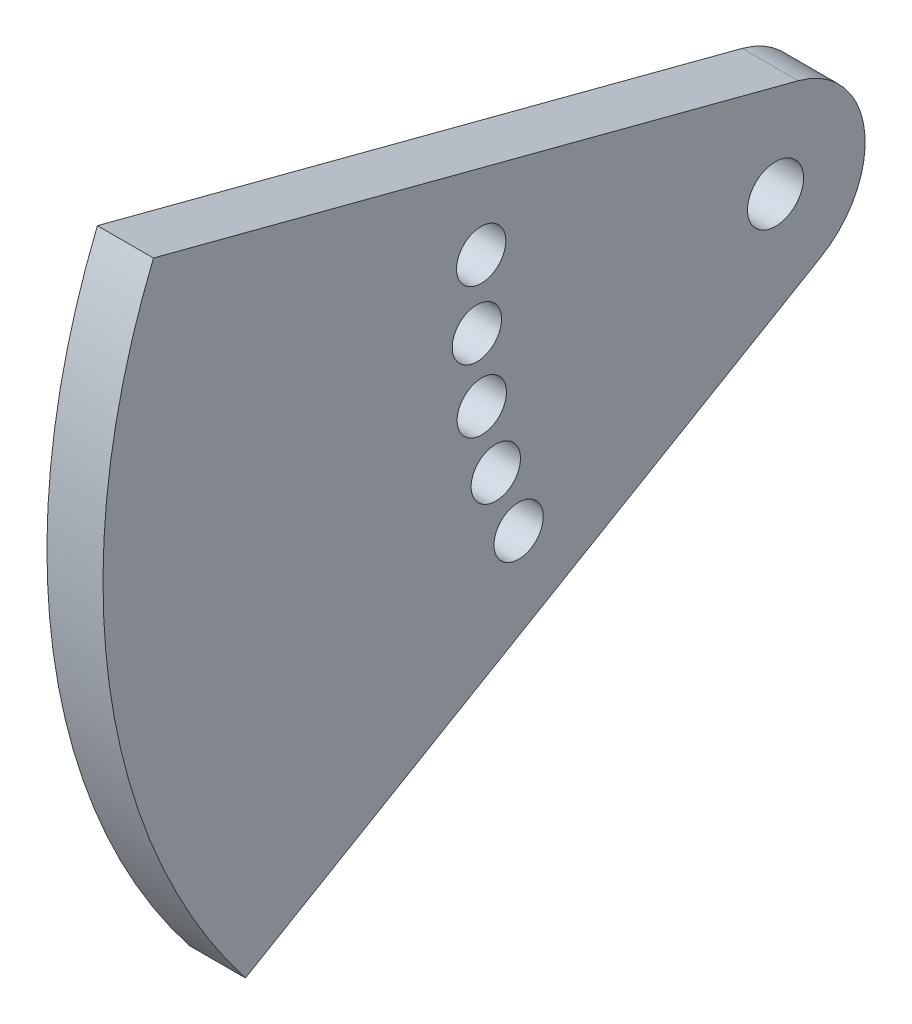
from build123d import *

# Parameters (mm, degrees)
SKETCH1_R           = 2.794
SKETCH1_R_2         = 3.175
BOSS_EXTRUDE1_DEPTH = 6.35


with BuildPart() as part:
    # Sketch1 → Boss-Extrude1 (new body)
    with BuildSketch(Plane(origin=(0, 0, 0), x_dir=(0, 0, -1), z_dir=(1, 0, 0))):
        with BuildLine():
            Line((2.573887506, 9.828565669), (-70.482178955, 28.960359974))
            ThreePointArc((-70.482178955, 28.960359974), (-75.490460705, -10.374504448), (-60.056829366, -46.900077255))
            Line((-60.056829366, -46.900077255), (5.129832124, -8.769858743))
            ThreePointArc((5.129832124, -8.769858743), (10.065394761, 1.38326726), (2.573887506, 9.828565669))
        make_face()
        with Locations((-33.347167041, 10.699986838)):
            Circle(SKETCH1_R, mode=Mode.SUBTRACT)
        with Locations((-33.832816449, 3.25056569)):
            Circle(SKETCH1_R, mode=Mode.SUBTRACT)
        with Locations((-33.276980509, -4.193947538)):
            Circle(SKETCH1_R, mode=Mode.SUBTRACT)
        with Locations((-31.690477935, -11.488653864)):
            Circle(SKETCH1_R, mode=Mode.SUBTRACT)
        with Locations((-29.104188196, -18.491570126)):
            Circle(SKETCH1_R, mode=Mode.SUBTRACT)
        Circle(SKETCH1_R_2, mode=Mode.SUBTRACT)
    extrude(amount=BOSS_EXTRUDE1_DEPTH)


solid = part.part
